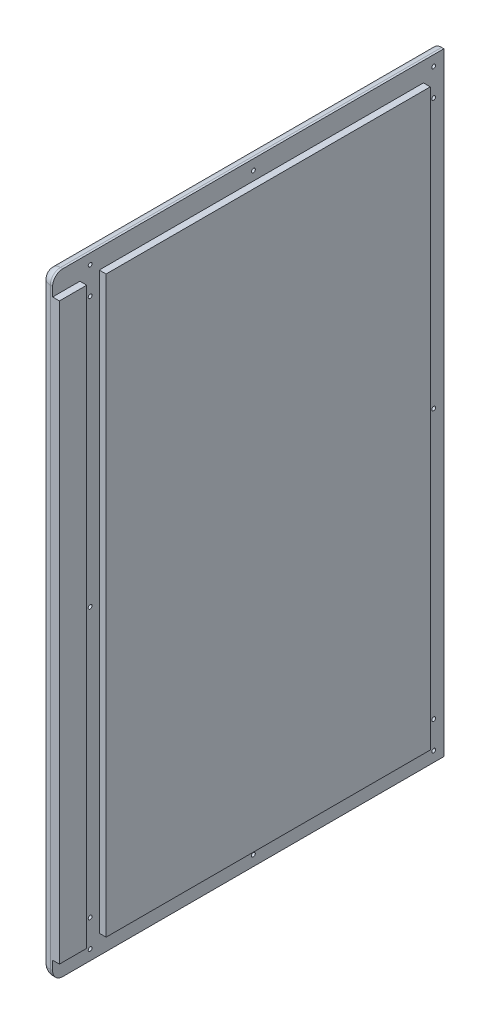
from build123d import *

# Parameters (mm, degrees)
SKETCH1_W           = 376.55000001
SKETCH1_H           = 570
BOSS_EXTRUDE1_DEPTH = 18
SKETCH5_W           = 18
SKETCH5_H           = 557.3
CUT_EXTRUDE3_DEPTH  = 6.35
SKETCH7_W           = 376.55000001
SKETCH7_H           = 18
CUT_EXTRUDE4_DEPTH  = 6.35
FILLET1_R           = 9.525
SKETCH9_W           = 19.05
SKETCH9_H           = 534
CUT_EXTRUDE6_DEPTH  = 6.35
SKETCH10_W          = 12.7
SKETCH10_H          = 570
CUT_EXTRUDE7_DEPTH  = 19
FILLET2_R           = 9.525
SKETCH11_R          = 1.7859375
CUT_EXTRUDE8_DEPTH  = 12.65


with BuildPart() as part:
    # Sketch1 → Boss-Extrude1 (new body)
    with BuildSketch(Plane(origin=(0, 0, 0), x_dir=(0, 0, -1), z_dir=(1, 0, 0))):
        with Locations((188.275000005, 285)):
            Rectangle(SKETCH1_W, SKETCH1_H)
    extrude(amount=BOSS_EXTRUDE1_DEPTH)

    # Sketch5 → Cut-Extrude3 (cut)
    with BuildSketch(Plane(origin=(18, 0, 0), x_dir=(0, 0, -1), z_dir=(1, 0, 0))):
        with Locations((47.1, 285)):
            Rectangle(SKETCH5_W, SKETCH5_H)
    extrude(amount=-CUT_EXTRUDE3_DEPTH, mode=Mode.SUBTRACT)

    # Sketch7 → Cut-Extrude4 (cut)
    with BuildSketch(Plane(origin=(18, 0, 0), x_dir=(0, 0, -1), z_dir=(1, 0, 0))):
        with Locations((188.275000005, 9)):
            Rectangle(SKETCH7_W, SKETCH7_H)
        with Locations((188.275000005, 561)):
            Rectangle(SKETCH7_W, SKETCH7_H)
    extrude(amount=-CUT_EXTRUDE4_DEPTH, mode=Mode.SUBTRACT)

    # Fillet1
    fillet1_edges = [part.edges().sort_by_distance(p)[0] for p in [
        (5.825, 0, 0),
        (0, 570, -188.275000005),
        (0, 0, -188.275000005),
        (5.825, 570, 0),
        (0, 285, 0),
    ]]
    fillet(fillet1_edges, radius=FILLET1_R)

    # Sketch9 → Cut-Extrude6 (cut)
    with BuildSketch(Plane(origin=(18, 0, 0), x_dir=(0, 0, -1), z_dir=(1, 0, 0))):
        with Locations((367.02500001, 285)):
            Rectangle(SKETCH9_W, SKETCH9_H)
    extrude(amount=-CUT_EXTRUDE6_DEPTH, mode=Mode.SUBTRACT)

    # Sketch10 → Cut-Extrude7 (cut, through all)
    with BuildSketch(Plane(origin=(18, 0, 0), x_dir=(0, 0, -1), z_dir=(1, 0, 0))):
        with Locations((6.35, 285)):
            Rectangle(SKETCH10_W, SKETCH10_H)
    extrude(amount=-CUT_EXTRUDE7_DEPTH, mode=Mode.SUBTRACT)

    # Fillet2
    fillet2_edges = [part.edges().sort_by_distance(p)[0] for p in [
        (2.789807909, 2.789807909, -12.7),
        (0, 285, -12.7),
        (10.5875, 570, -12.7),
        (2.789807909, 567.210192091, -12.7),
        (10.5875, 0, -12.7),
    ]]
    fillet(fillet2_edges, radius=FILLET2_R)

    # Sketch11 → Cut-Extrude8 (cut, through all)
    with BuildSketch(Plane(origin=(11.65, 0, 0), x_dir=(0, 0, -1), z_dir=(1, 0, 0))):
        with Locations((47.625, 285)):
            Circle(SKETCH11_R)
        with Locations((47.625, 560.475)):
            Circle(SKETCH11_R)
        with Locations((199.387500005, 560.475)):
            Circle(SKETCH11_R)
        with Locations((367.02500001, 560.475)):
            Circle(SKETCH11_R)
        with Locations((367.02500001, 285)):
            Circle(SKETCH11_R)
        with Locations((367.02500001, 9.525)):
            Circle(SKETCH11_R)
        with Locations((199.387500005, 9.525)):
            Circle(SKETCH11_R)
        with Locations((47.625, 9.525)):
            Circle(SKETCH11_R)
        with Locations((47.625, 34.925)):
            Circle(SKETCH11_R)
        with Locations((367.02500001, 34.925)):
            Circle(SKETCH11_R)
        with Locations((47.625, 535.075)):
            Circle(SKETCH11_R)
        with Locations((367.02500001, 535.075)):
            Circle(SKETCH11_R)
    extrude(amount=-CUT_EXTRUDE8_DEPTH, mode=Mode.SUBTRACT)


solid = part.part
